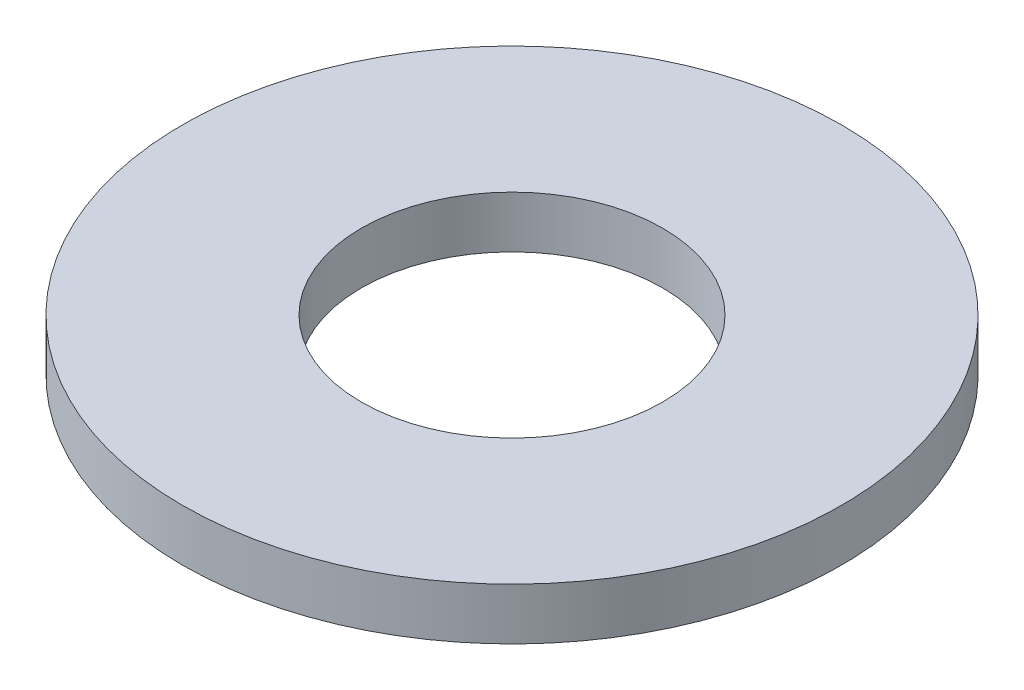
from build123d import *

# Parameters (mm, degrees)
SKETCH1_R           = 3.5
SKETCH1_R_2         = 1.6
BOSS_EXTRUDE1_DEPTH = 0.55


with BuildPart() as part:
    # Sketch1 → Boss-Extrude1 (new body)
    with BuildSketch(Plane(origin=(0, 0, 0), x_dir=(1, 0, 0), z_dir=(0, 1, 0))):
        Circle(SKETCH1_R)
        Circle(SKETCH1_R_2, mode=Mode.SUBTRACT)
    extrude(amount=BOSS_EXTRUDE1_DEPTH)


solid = part.part
